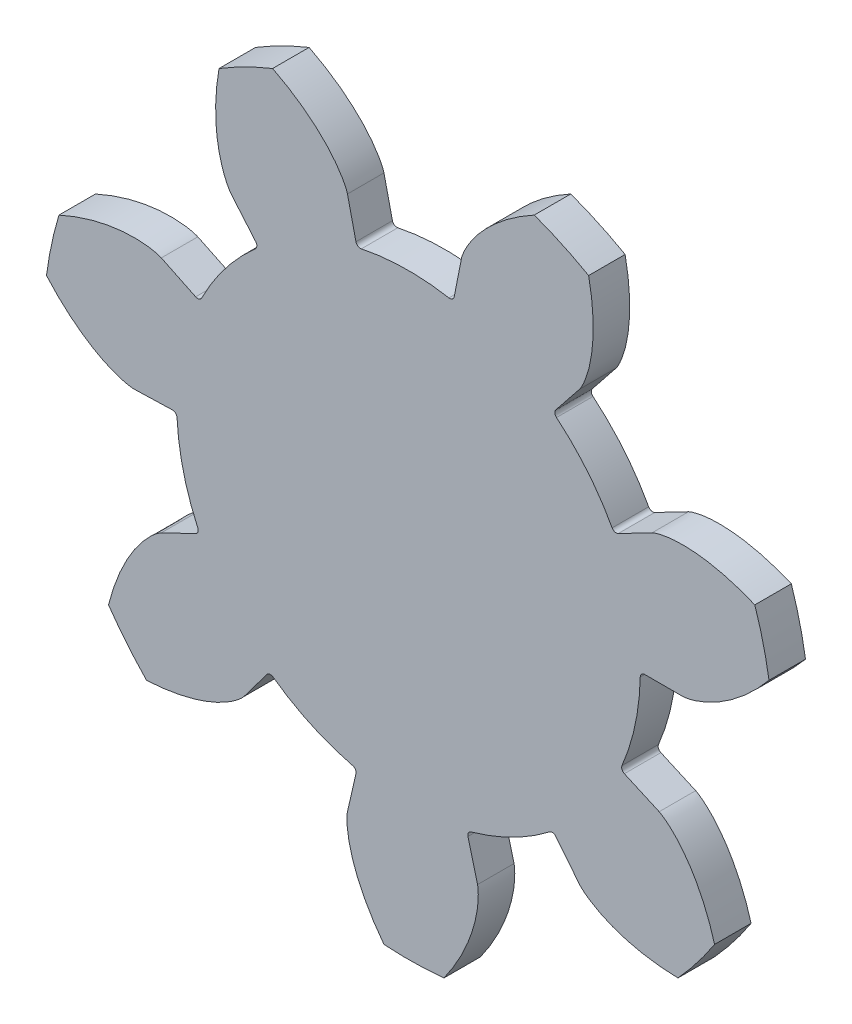
from build123d import *

# Parameters (mm, degrees)
SKETCH1_R                = 254
BOSS_EXTRUDE1_DEPTH      = 25.4
CUT_EXTRUDE1_START       = -26.4
CUT_EXTRUDE1_DEPTH       = 27.4
FILLET1_R                = 3.175
CIRPATTERN1_COUNT        = 7
FILLET1_OF_CIRPATTERN1_R = 3.175


with BuildPart() as part:
    # Sketch1 → Boss-Extrude1 (new body)
    with BuildSketch(Plane.XY):
        Circle(SKETCH1_R)
    extrude(amount=-BOSS_EXTRUDE1_DEPTH)

    # Sketch2 → Cut-Extrude1 (cut)
    with BuildSketch(Plane.XY.offset(CUT_EXTRUDE1_START)):
        with BuildLine():
            Line((190.945540544, 0), (161.29, 0))
            ThreePointArc((161.29, 0), (157.763562416, -33.542845344), (147.338453422, -65.618932048))
            Line((147.338453422, -65.618932048), (174.428796773, -77.683938557))
            add(Edge.make_bspline(
                [(174.428796773, -77.683938557), (174.4928263, -77.713661279), (174.61997868, -77.774971462), (174.971926635, -77.956695738), (175.624446174, -78.325021742), (176.604412814, -78.933671435), (177.891170724, -79.819473674), (179.505370021, -81.038813594), (181.34220225, -82.565746396), (183.28893252, -84.337903896), (185.32596251, -86.362343635), (187.284025888, -88.467007949), (189.165605373, -90.640202894), (190.974320999, -92.874307304), (193.084234026, -95.651631427), (195.502238964, -99.094374024), (198.155212887, -103.245382923), (200.961954953, -108.143150998), (203.588797888, -113.257878968), (205.993162502, -118.480725816), (207.909674737, -123.132088005), (209.423333335, -127.169369035), (210.600715227, -130.563461463), (211.493135033, -133.295949635), (212.197962967, -135.591346147), (212.670081746, -137.207432774), (212.933478125, -138.13544434), (213.000218992, -138.372348066)],
                knots=[0, 0, 0, 0, 0, 0.002688374, 0.005376748, 0.015083688, 0.02853182, 0.046610139, 0.064854849, 0.092110525, 0.119476175, 0.146842495, 0.174208853, 0.201574955, 0.228941013, 0.256307345, 0.307035032, 0.361767351, 0.41649966, 0.471231936, 0.525964281, 0.580696615, 0.608062798, 0.635428982, 0.662795184, 0.690161387, 0.699536091, 0.699536091, 0.699536091, 0.699536091, 0.699536091], degree=4))
            ThreePointArc((213.000218992, -138.372348066), (243.534448922, -72.159352741), (254, 0))
            ThreePointArc((254, 0), (253.216515608, 19.934799302), (250.87089588, 39.74661747))
            add(Edge.make_bspline(
                [(190.945540544, 0), (191.016123869, 0.001102055), (191.15722092, 0.005378472), (191.552657854, 0.028197799), (192.298583655, 0.099193762), (193.441405425, 0.256507655), (194.977237151, 0.542185774), (196.947882818, 0.999335428), (199.247043786, 1.64689495), (201.746364186, 2.473757773), (204.430810231, 3.494341204), (207.07576056, 4.62033937), (209.678720765, 5.840052262), (212.239904717, 7.145056933), (215.297227556, 8.823742597), (218.90672424, 10.984966695), (223.018988216, 13.697556266), (227.575574022, 17.029820986), (232.056020394, 20.633360828), (236.377331708, 24.426354483), (240.020302368, 27.895484684), (243.045731134, 30.968009879), (245.501824332, 33.589055642), (247.42928678, 35.722979997), (249.006071809, 37.531650702), (250.095462603, 38.816863444), (250.713616943, 39.557447778), (250.87089588, 39.74661747)],
                knots=[0, 0, 0, 0, 0, 0.002688374, 0.005376748, 0.015083688, 0.02853182, 0.046610139, 0.064854849, 0.092110525, 0.119476175, 0.146842495, 0.174208853, 0.201574955, 0.228941013, 0.256307345, 0.307035032, 0.361767351, 0.41649966, 0.471231936, 0.525964281, 0.580696615, 0.608062798, 0.635428982, 0.662795184, 0.690161387, 0.699532497, 0.699532497, 0.699532497, 0.699532497, 0.699532497], degree=4))
        make_face()
    cut_extrude1 = extrude(amount=CUT_EXTRUDE1_DEPTH, mode=Mode.SUBTRACT)

    # Fillet1
    fillet1_edges = [part.edges().sort_by_distance(p)[0] for p in [
        (161.29, 0, -12.7),
        (147.338453422, -65.618932048, -12.7),
    ]]
    fillet(fillet1_edges, radius=FILLET1_R)

    # CirPattern1: Cut-Extrude1 ×7 about axis
    cirpattern1_axis = Axis((0, 0, -25.4), (0, 0, 1))
    for i in range(1, CIRPATTERN1_COUNT):
        add(cut_extrude1.rotate(cirpattern1_axis, i * 360 / CIRPATTERN1_COUNT), mode=Mode.SUBTRACT)

    # Fillet1 of CirPattern1
    fillet1_of_cirpattern1_edges = [part.edges().sort_by_distance(p)[0] for p in [
        (100.562670142, 126.101599807, -12.7),
        (143.166970052, 74.281106523, -12.7),
        (-35.890401438, 157.246122956, -12.7),
        (31.187838158, 158.245956824, -12.7),
        (-145.317268704, 69.981108282, -12.7),
        (-104.276371984, 123.048374007, -12.7),
        (-145.317268704, -69.981108282, -12.7),
        (-161.218347172, -4.807144166, -12.7),
        (-35.890401438, -157.246122956, -12.7),
        (-96.759618685, -129.042784734, -12.7),
        (100.562670142, -126.101599807, -12.7),
        (40.561076209, -156.106576405, -12.7),
    ]]
    fillet(fillet1_of_cirpattern1_edges, radius=FILLET1_OF_CIRPATTERN1_R)


solid = part.part
